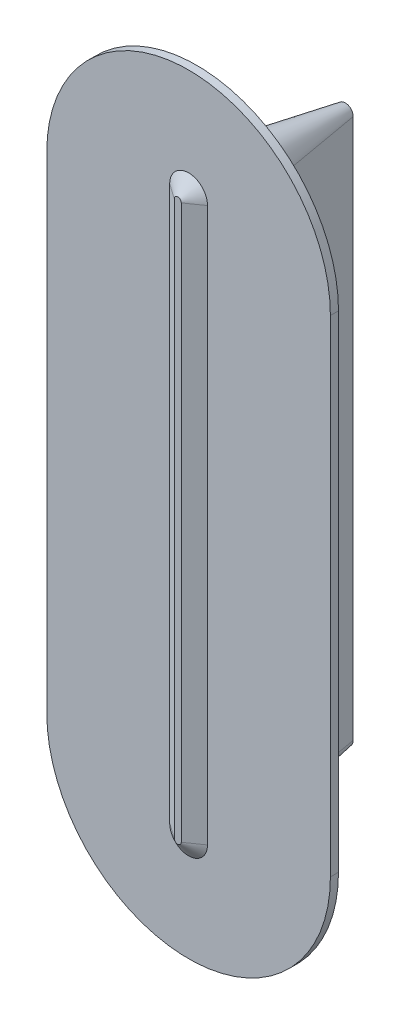
from build123d import *

# Parameters (mm, degrees)
BOSS_EXTRUDE1_DEPTH           = 15
BOSS_EXTRUDE1_OTHER_WAY_DEPTH = 40
BOSS_EXTRUDE1_OTHER_WAY_TAPER = 10
BOSS_EXTRUDE2_DEPTH           = 3
BOSS_EXTRUDE3_DEPTH           = 4
BOSS_EXTRUDE3_TAPER           = 55


with BuildPart() as part:
    # Sketch1 → Boss-Extrude1 (new body)
    with BuildSketch(Plane.XY):
        with BuildLine():
            ThreePointArc((-10, -100), (0, -110), (10, -100))
            Line((10, -100), (10, 100))
            ThreePointArc((10, 100), (0, 110), (-10, 100))
            Line((-10, 100), (-10, -100))
        make_face()
    extrude(amount=BOSS_EXTRUDE1_DEPTH)

    # Sketch1 → Boss-Extrude1 other way (add)
    with BuildSketch(Plane.XY):
        with BuildLine():
            ThreePointArc((-10, -100), (0, -110), (10, -100))
            Line((10, -100), (10, 100))
            ThreePointArc((10, 100), (0, 110), (-10, 100))
            Line((-10, 100), (-10, -100))
        make_face()
    extrude(amount=-BOSS_EXTRUDE1_OTHER_WAY_DEPTH, taper=BOSS_EXTRUDE1_OTHER_WAY_TAPER)

    # Sketch2 → Boss-Extrude2 (add)
    with BuildSketch(Plane.XY.offset(15)):
        with BuildLine():
            Line((-52.5, -90), (-52.5, 90))
            ThreePointArc((-52.5, 90), (0, 142.5), (52.5, 90))
            Line((52.5, 90), (52.5, -90))
            ThreePointArc((52.5, -90), (0, -142.5), (-52.5, -90))
        make_face()
    extrude(amount=BOSS_EXTRUDE2_DEPTH)

    # Sketch3 → Boss-Extrude3 (add)
    with BuildSketch(Plane.XY.offset(18)):
        with BuildLine():
            ThreePointArc((-7, -102.5), (0, -109.5), (7, -102.5))
            Line((7, -102.5), (7, 102.5))
            ThreePointArc((7, 102.5), (0, 109.5), (-7, 102.5))
            Line((-7, 102.5), (-7, -102.5))
        make_face()
    extrude(amount=BOSS_EXTRUDE3_DEPTH, taper=BOSS_EXTRUDE3_TAPER)


solid = part.part
